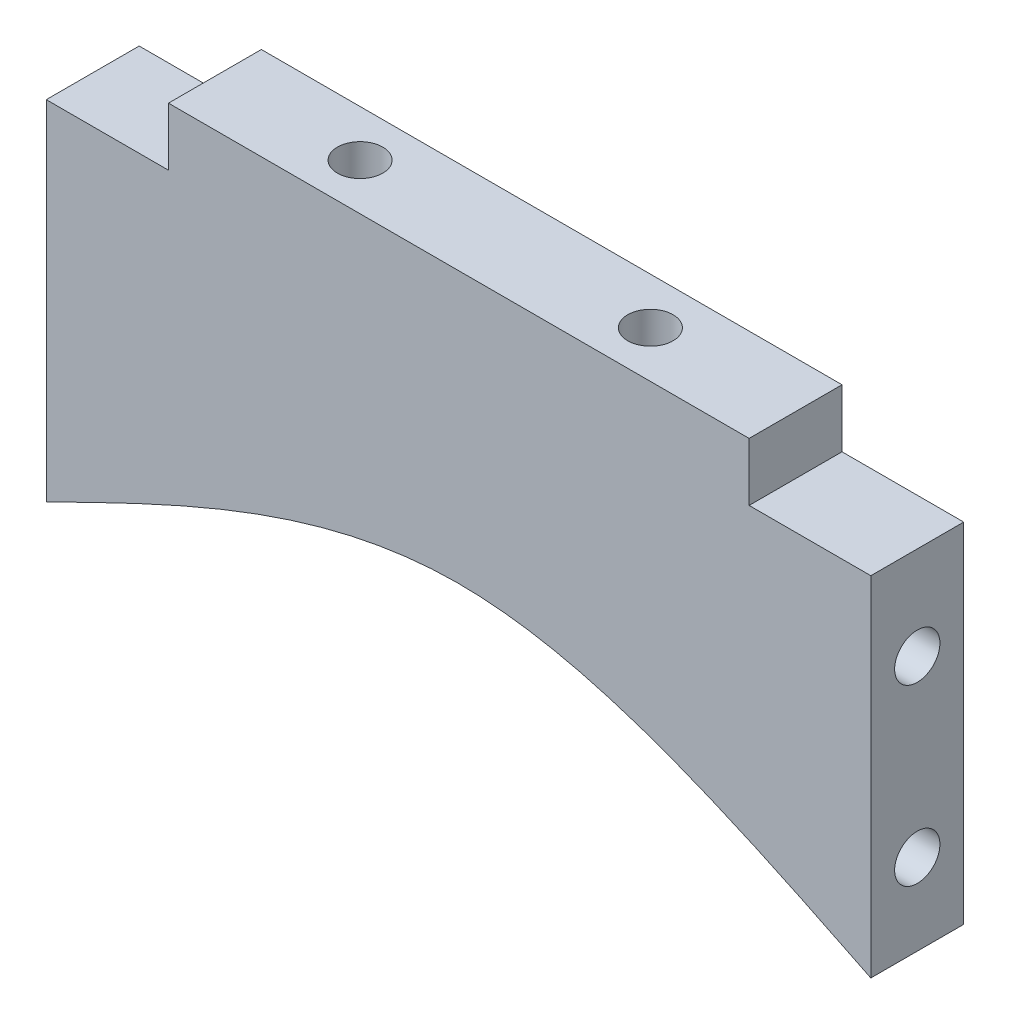
from build123d import *

# Parameters (mm, degrees)
EXTRUDE1_DEPTH = 8
EXTRUDE2_DEPTH = 8
SKETCH3_R      = 1.95
EXTRUDE3_DEPTH = 15
SKETCH4_R      = 1.95
EXTRUDE4_DEPTH = 10
SKETCH5_R      = 1.95
EXTRUDE5_DEPTH = 10


with BuildPart() as part:
    # Sketch1 → Extrude1 (new body)
    with BuildSketch(Plane.XY):
        Polygon((-45.778459293, 10.844789824), (-35.257703973, 10.844789824), (-35.257703973, 15.844789824), (14.742296027, 15.844789824), (14.742296027, 10.844789824), (25.221540707, 10.844789824), (25.221540707, -19.155210176), (-45.778459293, -19.155210176), align=None)
    extrude(amount=EXTRUDE1_DEPTH)

    # Sketch2 → Extrude2 (cut)
    with BuildSketch(Plane.XY.offset(8)):
        with BuildLine():
            Line((-45.778459293, -19.155210176), (25.221540707, -19.155210176))
            add(Edge.make_bspline(
                [(-45.778459293, -19.155210176), (-33.94270631, -13.318817895), (-10.275364533, -1.648086759), (13.390626945, -13.320186926), (25.221540707, -19.155210176)],
                knots=[0, 0, 0, 0, 0.500087973, 1, 1, 1, 1], degree=3))
        make_face()
    extrude(amount=-EXTRUDE2_DEPTH, mode=Mode.SUBTRACT)

    # Sketch3 → Extrude3 (cut)
    with BuildSketch(Plane(origin=(0, 15.844789824, 0), x_dir=(-1, 0, 0), z_dir=(0, 1, 0))):
        with Locations((22.757703973, 4)):
            Circle(SKETCH3_R)
        with Locations((-2.242296027, 4)):
            Circle(SKETCH3_R)
    extrude(amount=-EXTRUDE3_DEPTH, mode=Mode.SUBTRACT)

    # Sketch4 → Extrude4 (cut)
    with BuildSketch(Plane(origin=(25.221540707, 0, 0), x_dir=(0, 0, -1), z_dir=(1, 0, 0))):
        with Locations((-4, 2.844789824)):
            Circle(SKETCH4_R)
        with Locations((-4, -12.155210176)):
            Circle(SKETCH4_R)
    extrude(amount=-EXTRUDE4_DEPTH, mode=Mode.SUBTRACT)

    # Sketch5 → Extrude5 (cut)
    with BuildSketch(Plane.ZY.offset(45.778459293)):
        with Locations((4, 2.844789824)):
            Circle(SKETCH5_R)
        with Locations((4, -12.155210176)):
            Circle(SKETCH5_R)
    extrude(amount=-EXTRUDE5_DEPTH, mode=Mode.SUBTRACT)


solid = part.part
